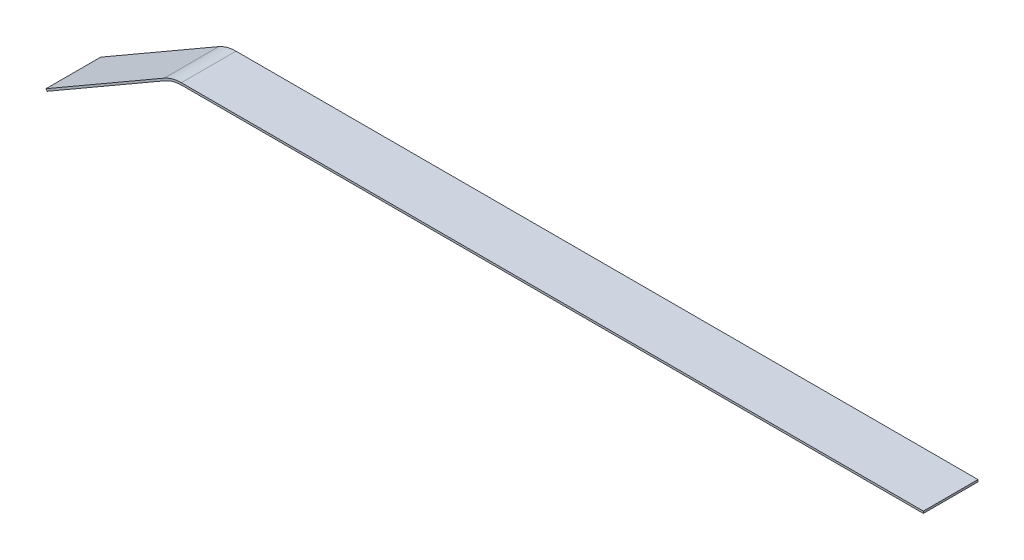
from build123d import *

# Parameters (mm, degrees)
BOSS_EXTRUDE1_DEPTH = 80


with BuildPart() as part:
    # Sketch1 → Boss-Extrude1 (new body)
    with BuildSketch(Plane.XY):
        with BuildLine():
            Line((-1284.807621135, -106.698729811), (-1111.602540378, -6.698729811))
            ThreePointArc((-1111.602540378, -6.698729811), (-1099.543492634, -1.703708686), (-1086.602540378, 0))
            Line((-1086.602540378, 0), (0, 0))
            Line((0, 0), (0, -3))
            Line((0, -3), (-1085.798692801, -3))
            ThreePointArc((-1085.798692801, -3), (-1098.739645056, -4.703708686), (-1110.798692801, -9.698729811))
            Line((-1110.798692801, -9.698729811), (-1283.307621135, -109.296806022))
            Line((-1283.307621135, -109.296806022), (-1284.807621135, -106.698729811))
        make_face()
    extrude(amount=BOSS_EXTRUDE1_DEPTH)


solid = part.part
